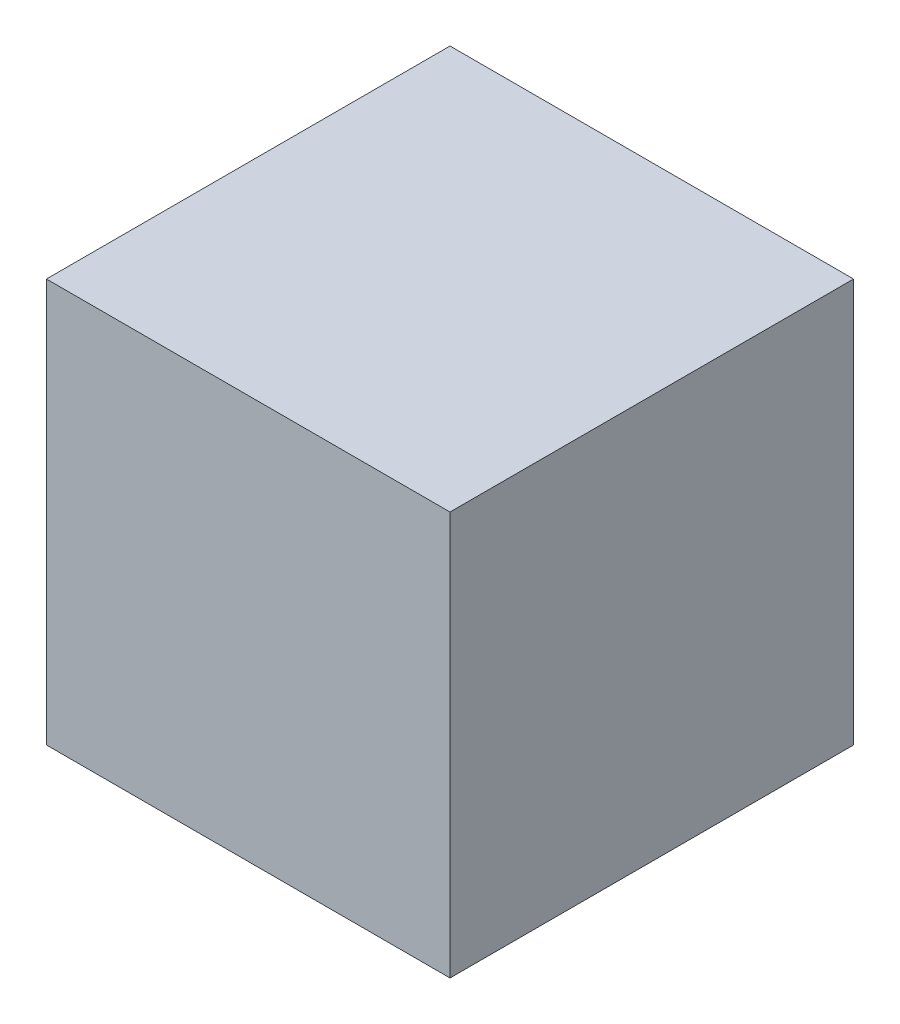
from build123d import *

# Parameters (mm, degrees)
SKETCH2_W           = 40
SKETCH2_H           = 40
BOSS_EXTRUDE1_DEPTH = 40


with BuildPart() as part:
    # Sketch2 → Boss-Extrude1 (new body)
    with BuildSketch(Plane.XY):
        Rectangle(SKETCH2_W, SKETCH2_H)
    extrude(amount=BOSS_EXTRUDE1_DEPTH)


solid = part.part
